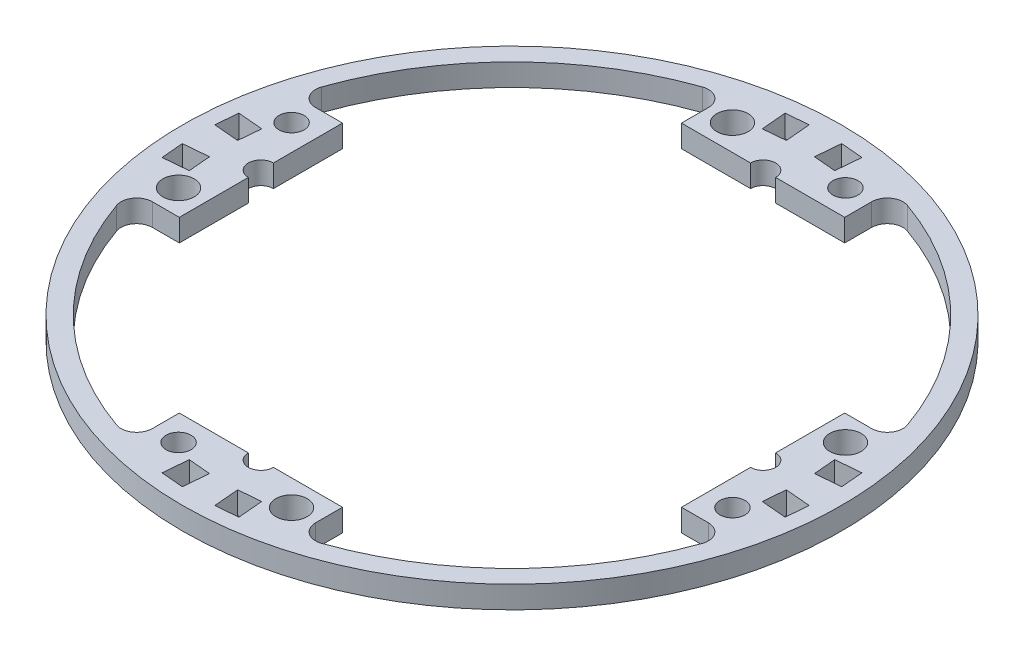
from build123d import *

# Parameters (mm, degrees)
BOSS_EXTRUDE1_DEPTH = 4.50088
CUT_EXTRUDE1_DEPTH  = 4.50088
CIRPATTERN1_COUNT   = 4
CUT_EXTRUDE3_DEPTH  = 5.50088
CIRPATTERN2_COUNT   = 4
SKETCH6_R           = 3.175
CUT_EXTRUDE4_DEPTH  = 5.50088
CIRPATTERN3_COUNT   = 4
SKETCH9_R           = 2.54
CUT_EXTRUDE5_DEPTH  = 5.50088
CIRPATTERN4_COUNT   = 4


with BuildPart() as part:
    # Sketch1 → Boss-Extrude1 (new body)
    with BuildSketch(Plane(origin=(0, 0, 0), x_dir=(1, 0, 0), z_dir=(0, 1, 0))):
        with BuildLine():
            Line((-66.675, 0), (-50.8, 0))
            Line((-50.8, 0), (-50.8, 16.51))
            Line((-50.8, 16.51), (-56.248410053, 16.51))
            ThreePointArc((-56.248410053, 16.51), (-58.837856989, 17.84777667), (-59.245192619, 20.733770352))
            ThreePointArc((-59.245192619, 20.733770352), (-44.384017853, 44.384017853), (-20.733770352, 59.245192619))
            ThreePointArc((-20.733770352, 59.245192619), (-17.84777667, 58.837856989), (-16.51, 56.248410053))
            Line((-16.51, 56.248410053), (-16.51, 50.8))
            Line((-16.51, 50.8), (0, 50.8))
            Line((0, 50.8), (0, 66.675))
            ThreePointArc((0, 66.675), (-47.146344636, 47.146344636), (-66.675, 0))
        make_face()
    boss_extrude1 = extrude(amount=BOSS_EXTRUDE1_DEPTH)

    # Sketch2 → Cut-Extrude1 (cut)
    with BuildSketch(Plane(origin=(0, 4.50088, 0), x_dir=(1, 0, 0), z_dir=(0, 1, 0))):
        Polygon((-63.024379444, 7.772955042), (-57.963710378, 7.330203869), (-58.355987918, 2.846451076), (-63.416656984, 3.28920225), align=None)
        Polygon((-7.330203869, 57.963710378), (-5.088327473, 58.159849148), (-5.531078646, 63.220518214), (-7.772955042, 63.024379444), align=None)
        Polygon((-5.531078646, 63.220518214), (-5.088327473, 58.159849148), (-2.846451076, 58.355987918), (-3.28920225, 63.416656984), align=None)
    cut_extrude1 = extrude(amount=-CUT_EXTRUDE1_DEPTH, mode=Mode.SUBTRACT)

    # CirPattern1: Boss-Extrude1, Cut-Extrude1 ×4 about axis
    cirpattern1_axis = Axis((0, 0, 0), (0, 1, 0))
    for i in range(1, CIRPATTERN1_COUNT):
        add(boss_extrude1.rotate(cirpattern1_axis, i * 360 / CIRPATTERN1_COUNT))
        add(cut_extrude1.rotate(cirpattern1_axis, i * 360 / CIRPATTERN1_COUNT), mode=Mode.SUBTRACT)

    # Sketch5 → Cut-Extrude3 (cut, through all)
    with BuildSketch(Plane(origin=(0, 4.50088, 0), x_dir=(1, 0, 0), z_dir=(0, 1, 0))):
        with BuildLine():
            Line((-2.54, 50.8), (2.54, 50.8))
            ThreePointArc((2.54, 50.8), (0, 53.34), (-2.54, 50.8))
        make_face()
    cut_extrude3 = extrude(amount=-CUT_EXTRUDE3_DEPTH, mode=Mode.SUBTRACT)

    # CirPattern2: Cut-Extrude3 ×4 about axis
    cirpattern2_axis = Axis((0, 0, 0), (0, 1, 0))
    for i in range(1, CIRPATTERN2_COUNT):
        add(cut_extrude3.rotate(cirpattern2_axis, i * 360 / CIRPATTERN2_COUNT), mode=Mode.SUBTRACT)

    # Sketch6 → Cut-Extrude4 (cut, through all)
    with BuildSketch(Plane(origin=(0, 4.50088, 0), x_dir=(1, 0, 0), z_dir=(0, 1, 0))):
        with Locations((-56.03313088, -11.43)):
            Circle(SKETCH6_R)
    cut_extrude4 = extrude(amount=-CUT_EXTRUDE4_DEPTH, mode=Mode.SUBTRACT)

    # CirPattern3: Cut-Extrude4 ×4 about axis
    cirpattern3_axis = Axis((0, 0, 0), (0, 1, 0))
    for i in range(1, CIRPATTERN3_COUNT):
        add(cut_extrude4.rotate(cirpattern3_axis, i * 360 / CIRPATTERN3_COUNT), mode=Mode.SUBTRACT)

    # Sketch9 → Cut-Extrude5 (cut, through all)
    with BuildSketch(Plane(origin=(0, 4.50088, 0), x_dir=(1, 0, 0), z_dir=(0, 1, 0))):
        with Locations((11.43, 56.03313088)):
            Circle(SKETCH9_R)
    cut_extrude5 = extrude(amount=-CUT_EXTRUDE5_DEPTH, mode=Mode.SUBTRACT)

    # CirPattern4: Cut-Extrude5 ×4 about axis
    cirpattern4_axis = Axis((0, 0, 0), (0, 1, 0))
    for i in range(1, CIRPATTERN4_COUNT):
        add(cut_extrude5.rotate(cirpattern4_axis, i * 360 / CIRPATTERN4_COUNT), mode=Mode.SUBTRACT)


solid = part.part
